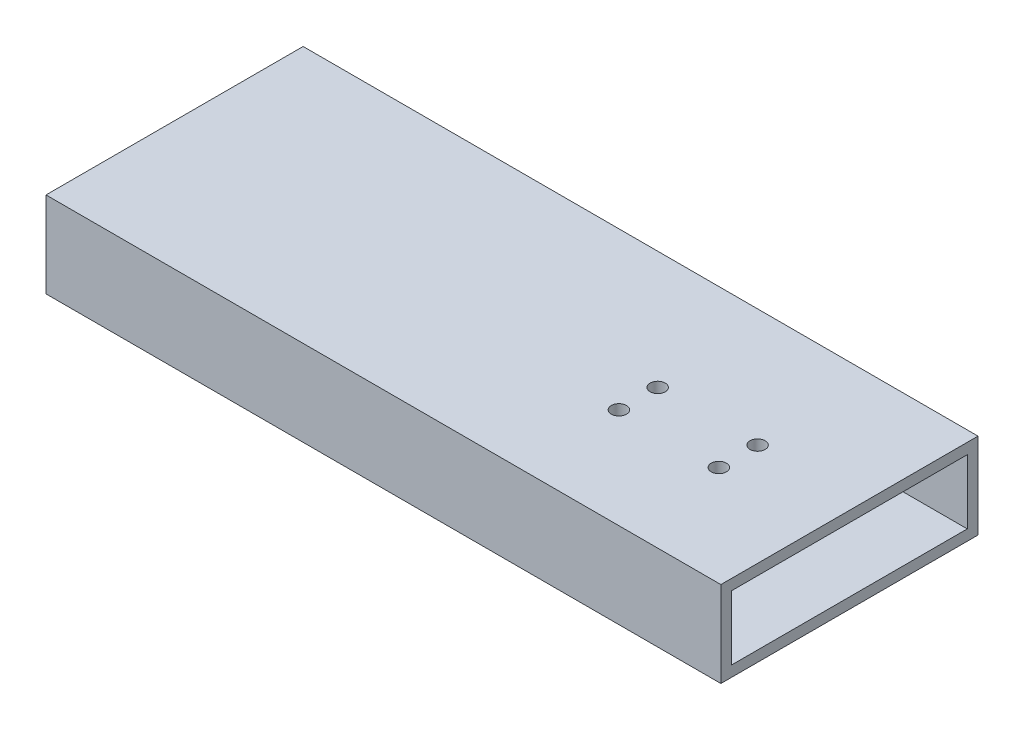
from build123d import *

# Parameters (mm, degrees)
SKETCH1_W            = 152.4
SKETCH1_H            = 50.8
SKETCH1_W_2          = 139.7
SKETCH1_H_2          = 38.1
BOSS_EXTRUDE1_DEPTH  = 400
M8_CLEARANCE_HOLE1_D = 9


with BuildPart() as part:
    # Sketch1 → Boss-Extrude1 (new body)
    with BuildSketch(Plane(origin=(0, 0, 0), x_dir=(0, 0, -1), z_dir=(1, 0, 0))):
        Rectangle(SKETCH1_W, SKETCH1_H)
        Rectangle(SKETCH1_W_2, SKETCH1_H_2, mode=Mode.SUBTRACT)
    extrude(amount=BOSS_EXTRUDE1_DEPTH)

    # M8 Clearance Hole1 (through all)
    with Locations(Plane(origin=(0, -25.4, 0), x_dir=(-1, 0, 0), z_dir=(0, -1, 0))):
        with Locations((-280.09, -16.73), (-280.09, 6.27), (-339.29, 6.27), (-339.29, -16.73)):
            Hole(M8_CLEARANCE_HOLE1_D / 2)


solid = part.part
